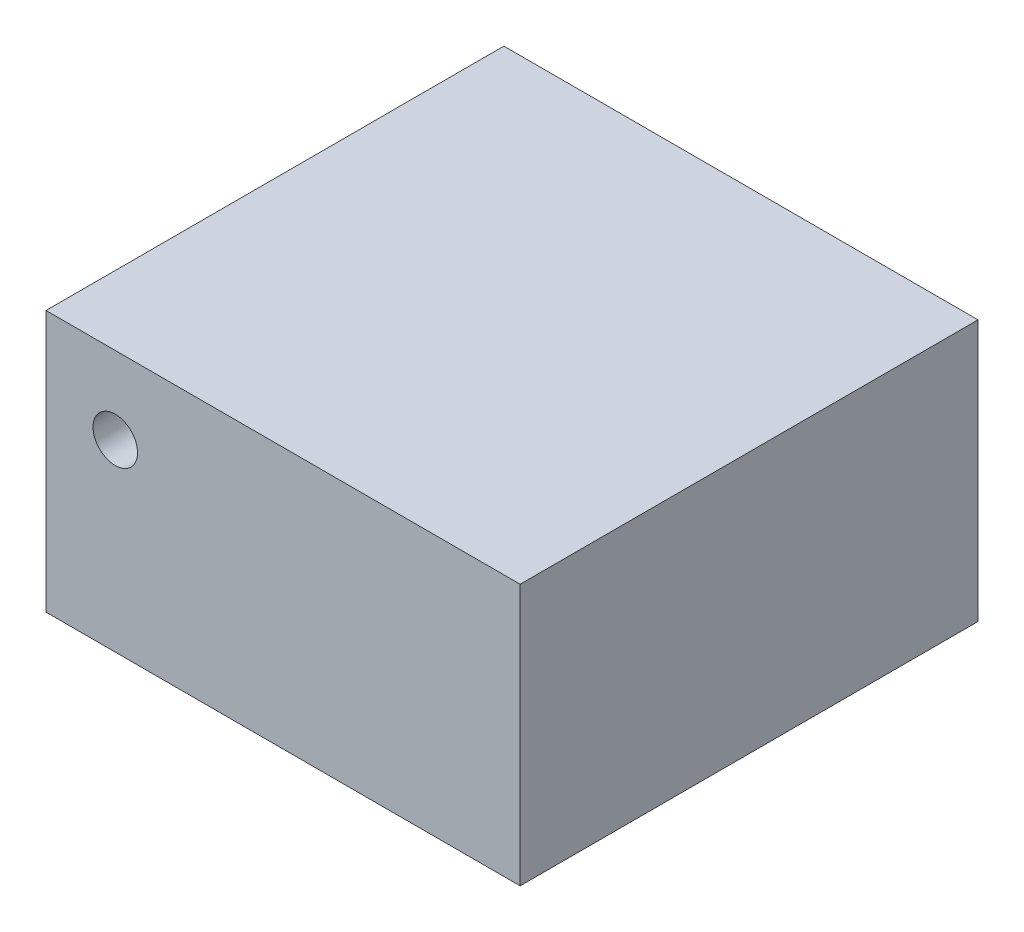
from build123d import *

# Parameters (mm, degrees)
SKETCH1_W            = 31.115
SKETCH1_H            = 17.145
MOTOR_BODY_DEPTH     = 30.0482
FASTENING_HOLE_DEPTH = 1.9812
SKETCH3_R            = 1.4605
SHAFT_HOLE_DEPTH     = 31.0482


with BuildPart() as part:
    # Sketch1 → Motor Body (new body)
    with BuildSketch(Plane.XY):
        Rectangle(SKETCH1_W, SKETCH1_H)
    extrude(amount=MOTOR_BODY_DEPTH)

    # Sketch2 → Fastening hole (add)
    with BuildSketch(Plane.XZ.offset(8.5725)):
        with BuildLine():
            Line((-0.8763, -7.4676), (5.5245, -7.4676))
            ThreePointArc((5.5245, -7.4676), (6.422525612, -7.095625612), (6.7945, -6.1976))
            Line((6.7945, -6.1976), (6.7945, 0))
            Line((6.7945, 0), (-2.1463, 0))
            Line((-2.1463, 0), (-2.1463, -6.1976))
            ThreePointArc((-2.1463, -6.1976), (-1.774325612, -7.095625612), (-0.8763, -7.4676))
        make_face()
        with BuildLine():
            Line((0.6858, -5.4356), (3.8862, -5.4356))
            ThreePointArc((3.8862, -5.4356), (4.784225612, -5.063625612), (5.1562, -4.1656))
            Line((5.1562, -4.1656), (5.1562, -3.5306))
            ThreePointArc((5.1562, -3.5306), (4.784225612, -2.632574388), (3.8862, -2.2606))
            Line((3.8862, -2.2606), (0.6858, -2.2606))
            ThreePointArc((0.6858, -2.2606), (-0.212225612, -2.632574388), (-0.5842, -3.5306))
            Line((-0.5842, -3.5306), (-0.5842, -4.1656))
            ThreePointArc((-0.5842, -4.1656), (-0.212225612, -5.063625612), (0.6858, -5.4356))
        make_face(mode=Mode.SUBTRACT)
    extrude(amount=-FASTENING_HOLE_DEPTH)

    # Sketch3 → Shaft hole (cut, through all)
    with BuildSketch(Plane(origin=(0, 0, 0), x_dir=(-1, 0, 0), z_dir=(0, 0, -1))):
        with Locations((11.0109, 3.4925)):
            Circle(SKETCH3_R)
    extrude(amount=-SHAFT_HOLE_DEPTH, mode=Mode.SUBTRACT)


solid = part.part
